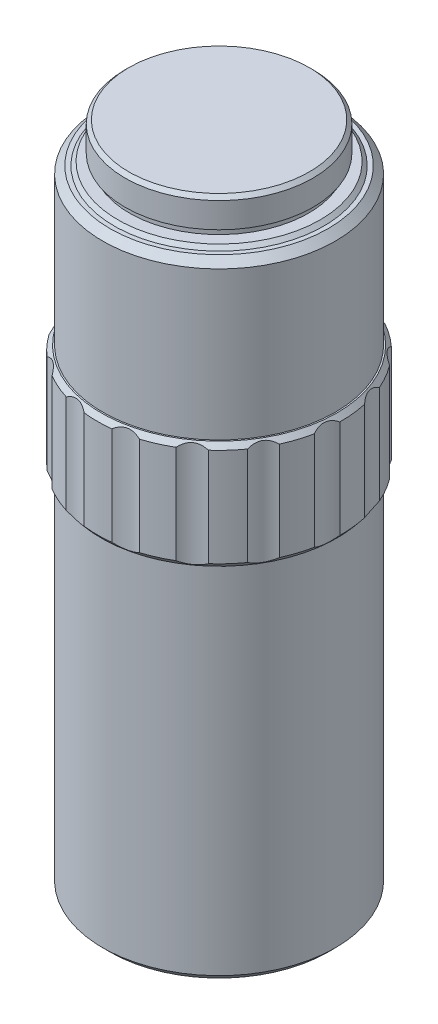
from build123d import *

# Parameters (mm, degrees)
SCALE_1_SCALE       = 2
SKETCH_2_R          = 4
CUT_EXTRUDE_1_DEPTH = 93.200466651


with BuildPart() as part:
    # 草图1 → 旋转1 (revolve)
    with BuildSketch(Plane.XY):
        Polygon((-5.875, -23.10087525), (-5.725, -23.25087525), (0, -23.25087525), (0, 23.25087525), (-4.75, 23.25087525), (-6, 23.25087525), (-6.25, 23.25087525), (-6.5, 23.00087525), (-6.5, 21.25087525), (-6.2, 21.25087525), (-6.2, 20.75087525), (-7, 20.75087525), (-7.25, 20.50087525), (-7.55, 20.50087525), (-8.05, 20.00087525), (-8.05, 9.75087525), (-8.15, 9.75087525), (-8.436111111, 9.40087525), (-8.436111111, 2.60087525), (-8.15, 2.25087525), (-8.05, 2.25087525), (-8.05, -22.349358076), (-7.55, -22.849358076), (-5.875, -22.849358076), align=None)
    revolve(axis=Axis((0, 23.25087525, 0), (0, -1, 0)))


with BuildPart() as part_1:
    # 缩放比例1: scaled about (0, -0.26757776, 0)
    add(part.part.scale(SCALE_1_SCALE).moved(Location((0, 0.26757776, 0))))

    # 草图2 → 切除-拉伸1 (cut, through all)
    with BuildSketch(Plane(origin=(0, -45.431138391, 0), x_dir=(-1, 0, 0), z_dir=(0, -1, 0))):
        with Locations((0, 20.461460378)):
            Circle(SKETCH_2_R)
        with Locations((8.322425706, 18.692474185)):
            Circle(SKETCH_2_R)
        with Locations((15.205828401, 13.69138939)):
            Circle(SKETCH_2_R)
        with Locations((19.460005225, 6.322938986)):
            Circle(SKETCH_2_R)
        with Locations((20.349370357, -2.138805009)):
            Circle(SKETCH_2_R)
        with Locations((17.720144486, -10.230730189)):
            Circle(SKETCH_2_R)
        with Locations((12.02694465, -16.553669175)):
            Circle(SKETCH_2_R)
        with Locations((4.254176824, -20.014328376)):
            Circle(SKETCH_2_R)
        with Locations((-4.254176824, -20.014328376)):
            Circle(SKETCH_2_R)
        with Locations((-12.02694465, -16.553669175)):
            Circle(SKETCH_2_R)
        with Locations((-17.720144486, -10.230730189)):
            Circle(SKETCH_2_R)
        with Locations((-20.349370357, -2.138805009)):
            Circle(SKETCH_2_R)
        with Locations((-19.460005225, 6.322938986)):
            Circle(SKETCH_2_R)
        with Locations((-15.205828401, 13.69138939)):
            Circle(SKETCH_2_R)
        with Locations((-8.322425706, 18.692474185)):
            Circle(SKETCH_2_R)
    extrude(amount=-CUT_EXTRUDE_1_DEPTH, mode=Mode.SUBTRACT)


solid = part_1.part
